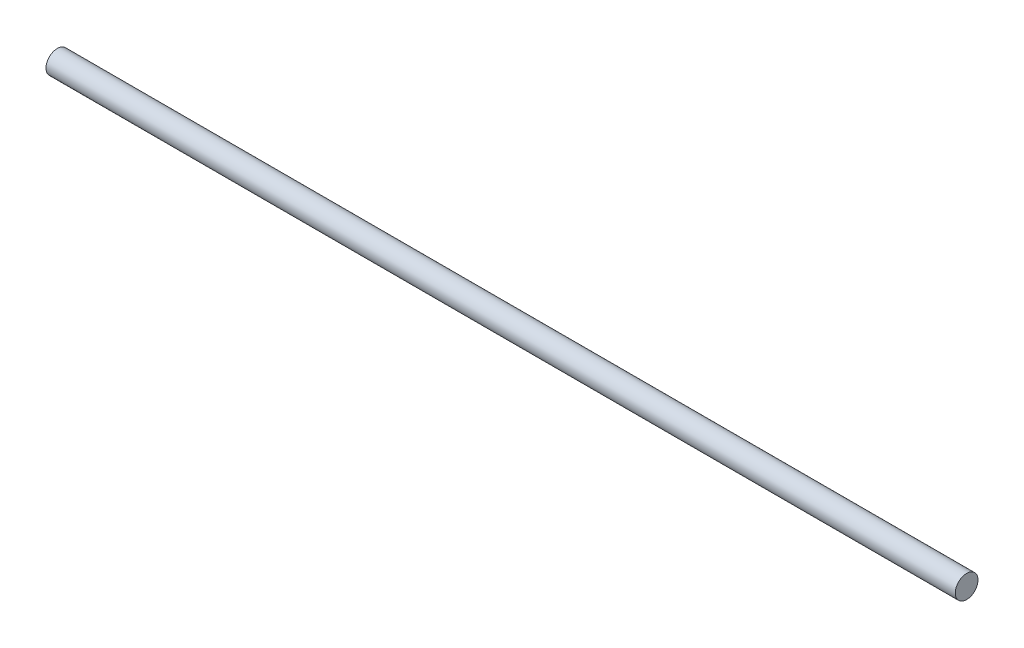
from build123d import *

# Parameters (mm, degrees)
SKETCH1_R           = 2.5
BOSS_EXTRUDE1_DEPTH = 100


with BuildPart() as part:
    # Sketch1 → Boss-Extrude1 (new body, symmetric)
    with BuildSketch(Plane(origin=(0, 0, 0), x_dir=(0, 0, -1), z_dir=(1, 0, 0))):
        Circle(SKETCH1_R)
    extrude(amount=BOSS_EXTRUDE1_DEPTH, both=True)


solid = part.part
